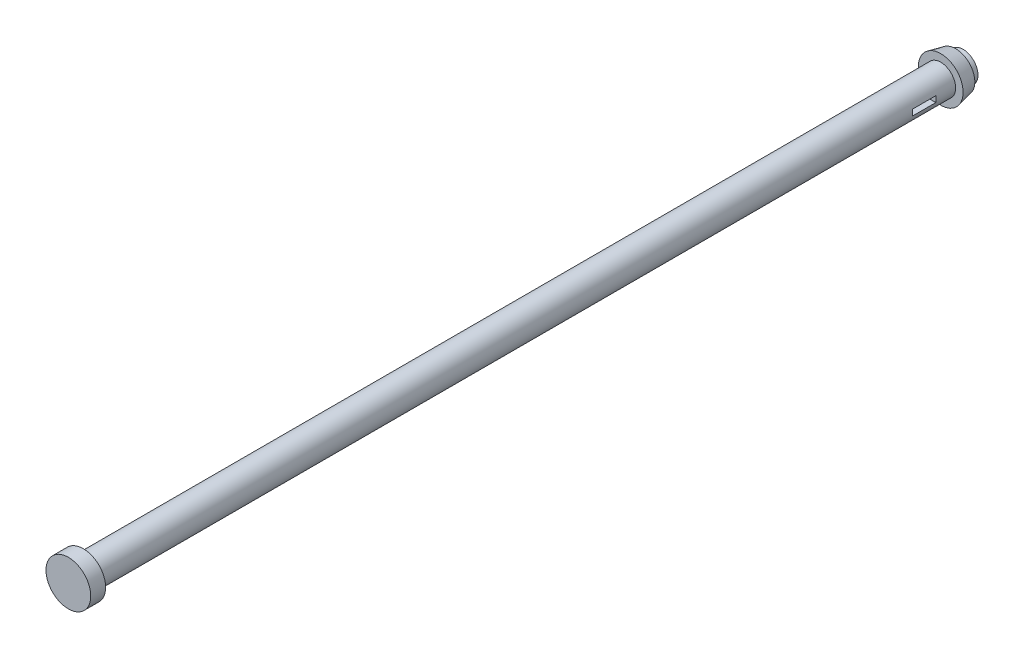
from build123d import *

# Parameters (mm, degrees)
SKETCH1_R               = 10
BOSS_EXTRUDE1_DEPTH     = 590
SKETCH2_R               = 15
BOSS_EXTRUDE2_DEPTH     = 10
SKETCH3_R               = 15
BOSS_EXTRUDE3_DEPTH     = 10
BOSS_EXTRUDE3_TAPER     = 12
BODY_MOVE_COPY1_ANGLE   = 90
CUT_EXTRUDE1_DEPTH      = 2
CUT_EXTRUDE1_DEPTH_BACK = 2
SKETCH4_W               = 20
SKETCH4_H               = 15.783753313


with BuildPart() as part:
    # Sketch1 → Boss-Extrude1 (new body)
    with BuildSketch(Plane(origin=(0, 0, 0), x_dir=(1, 0, 0), z_dir=(0, 1, 0))):
        Circle(SKETCH1_R)
    extrude(amount=BOSS_EXTRUDE1_DEPTH)

    # Sketch2 → Boss-Extrude2 (add)
    with BuildSketch(Plane(origin=(0, 590, 0), x_dir=(1, 0, 0), z_dir=(0, 1, 0))):
        Circle(SKETCH2_R)
    extrude(amount=BOSS_EXTRUDE2_DEPTH)

    # Sketch3 → Boss-Extrude3 (add)
    with BuildSketch(Plane(origin=(0, 15, 0), x_dir=(-1, 0, 0), z_dir=(0, -1, 0))):
        Circle(SKETCH3_R)
    extrude(amount=BOSS_EXTRUDE3_DEPTH, taper=BOSS_EXTRUDE3_TAPER)


with BuildPart() as part_1:
    # Body-Move_Copy1: moved
    add(part.part.rotate(Axis((0, 0, 0), (1, 0, 0)), BODY_MOVE_COPY1_ANGLE))

    # Sketch4 → Cut-Extrude1 (cut, two sides: drawn at the far end of the back side and taken through both)
    with BuildSketch(Plane(origin=(0, 0, 0), x_dir=(1, 0, 0), z_dir=(0, 1, 0)).offset(-CUT_EXTRUDE1_DEPTH_BACK)):
        with Locations((0, -35.976721821)):
            Rectangle(SKETCH4_W, SKETCH4_H)
    extrude(amount=CUT_EXTRUDE1_DEPTH + CUT_EXTRUDE1_DEPTH_BACK, mode=Mode.SUBTRACT)


solid = part_1.part
